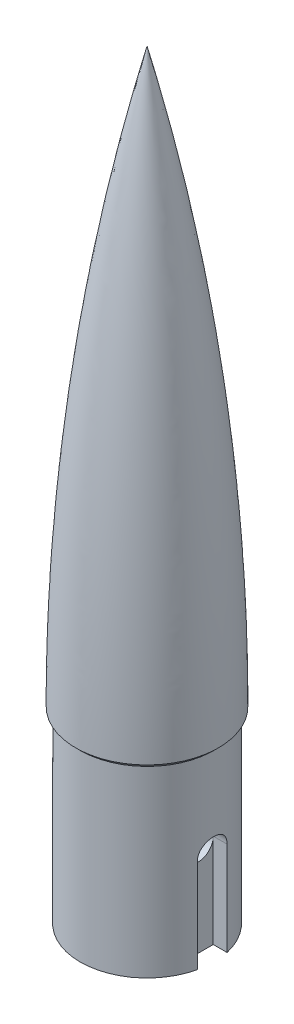
from build123d import *

# Parameters (mm, degrees)
SKETCH1_R               = 8.895
BOSS_EXTRUDE1_DEPTH     = 25
CUT_EXTRUDE1_DEPTH      = 12.5
SKETCH3_R               = 1.984375
CUT_EXTRUDE2_DEPTH      = 9.895
CUT_EXTRUDE2_DEPTH_BACK = 9.895
CHAMFER1_SIZE           = 0.6


with BuildPart() as part:
    # Sketch1 → Boss-Extrude1 (new body)
    with BuildSketch(Plane(origin=(0, 0, 0), x_dir=(1, 0, 0), z_dir=(0, 1, 0))):
        Circle(SKETCH1_R)
    extrude(amount=-BOSS_EXTRUDE1_DEPTH)

    # Sketch2 → Cut-Extrude1 (cut)
    with BuildSketch(Plane.XZ.offset(25)):
        with BuildLine():
            Line((-6.83125, 1.984375), (-6.83125, -1.984375))
            Line((-6.83125, -1.984375), (-8.670829306, -1.984375))
            ThreePointArc((-8.670829306, -1.984375), (-8.895, 0), (-8.670829306, 1.984375))
            Line((-8.670829306, 1.984375), (-6.83125, 1.984375))
        make_face()
    cut_extrude1 = extrude(amount=-CUT_EXTRUDE1_DEPTH, mode=Mode.SUBTRACT)

    # Mirror1: Cut-Extrude1 across plane
    add(cut_extrude1.mirror(Plane(origin=(0, 0, 0), x_dir=(0, 0, 1), z_dir=(1, 0, 0))), mode=Mode.SUBTRACT)

    # Sketch3 → Cut-Extrude2 (cut, two sides)
    with BuildSketch(Plane(origin=(0, 0, 0), x_dir=(0, 0, -1), z_dir=(1, 0, 0))) as cut_extrude2_sk:
        with Locations((0, -12.5)):
            Circle(SKETCH3_R)
    extrude(amount=CUT_EXTRUDE2_DEPTH, mode=Mode.SUBTRACT)
    extrude(cut_extrude2_sk.sketch, amount=-CUT_EXTRUDE2_DEPTH_BACK, mode=Mode.SUBTRACT)

    # Sketch4 → Revolve1 (revolve)
    with BuildSketch(Plane.XY):
        with BuildLine():
            Line((0, 0), (0, 76.2))
            ThreePointArc((0, 76.2), (7.115842324, 38.394954096), (9.5, 0))
            Line((9.5, 0), (0, 0))
        make_face()
    revolve(axis=Axis((0, 0, 0), (0, 1, 0)))

    # Chamfer1
    chamfer1_edges = [part.edges().sort_by_distance(p)[0] for p in [
        (-8.895, 0, 0),
    ]]
    chamfer(chamfer1_edges, length=CHAMFER1_SIZE)


solid = part.part
